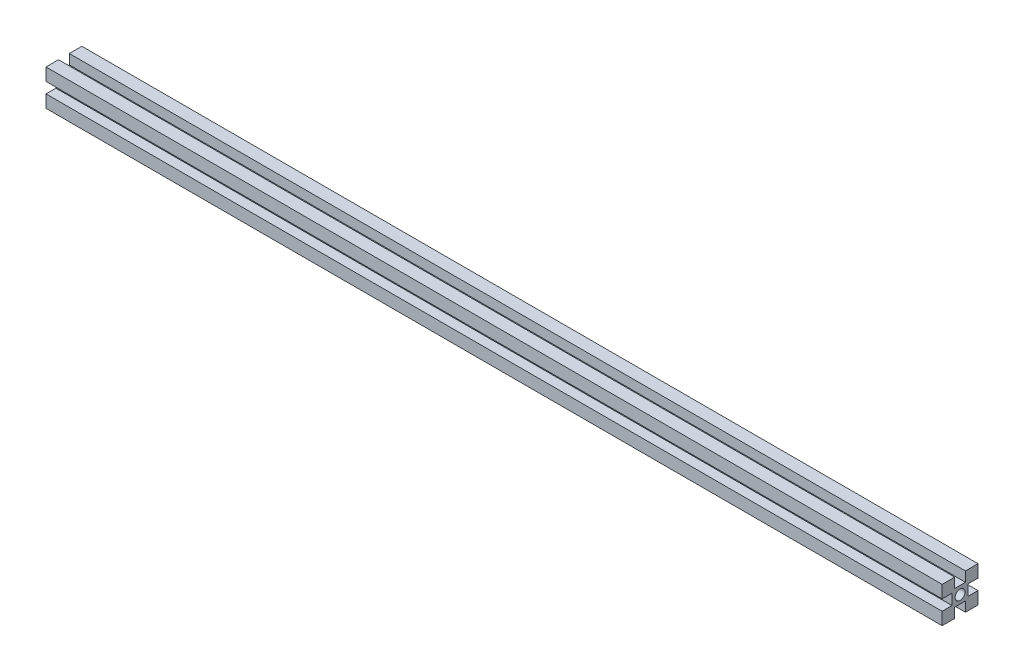
from build123d import *

# Parameters (mm, degrees)
ESQUISSE1_R        = 2.75
BOSS_EXTRU_1_DEPTH = 500


with BuildPart() as part:
    # Esquisse1 → Boss.-Extru.1 (new body)
    with BuildSketch(Plane(origin=(0, 0, 0), x_dir=(0, -1, 0), z_dir=(-1, 0, 0))):
        Polygon((-3, -10), (-3, -4.5), (3, -4.5), (3, -10), (10, -10), (10, -3), (4.5, -3), (4.5, 3), (10, 3), (10, 10), (3, 10), (3, 4.5), (-3, 4.5), (-3, 10), (-10, 10), (-10, 3), (-4.5, 3), (-4.5, -3), (-10, -3), (-10, -10), align=None)
        Circle(ESQUISSE1_R, mode=Mode.SUBTRACT)
    extrude(amount=-BOSS_EXTRU_1_DEPTH)


solid = part.part
